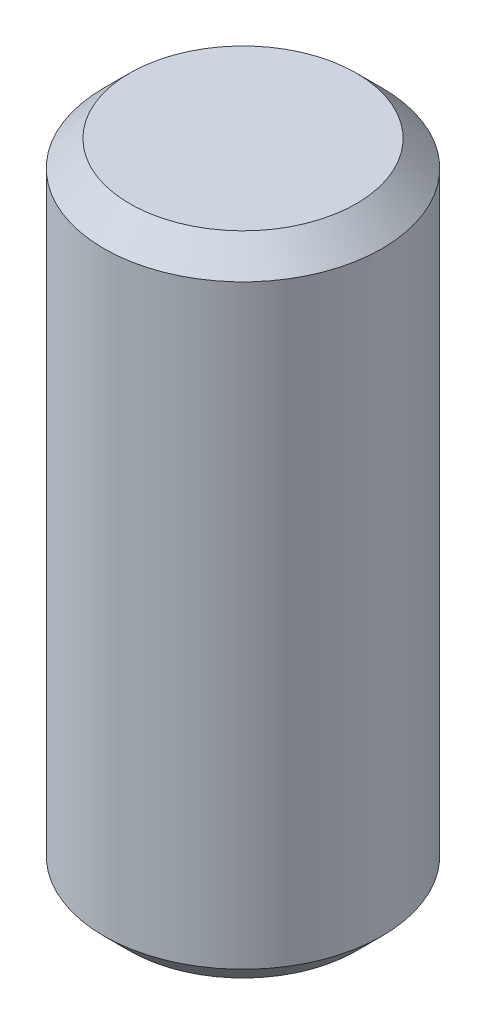
from build123d import *

# Parameters (mm, degrees)
SKETCH1_W     = 2.7305
SKETCH1_H     = 12.7
CHAMFER1_SIZE = 0.508


with BuildPart() as part:
    # Sketch1 → Revolve1 (revolve)
    with BuildSketch(Plane.XY):
        with Locations((1.36525, 0)):
            Rectangle(SKETCH1_W, SKETCH1_H)
    revolve(axis=Axis((0, 6.080207887, 0), (0, -1, 0)))

    # Chamfer1
    chamfer1_edges = [part.edges().sort_by_distance(p)[0] for p in [
        (-2.7305, 6.35, 0),
        (-2.7305, -6.35, 0),
    ]]
    chamfer(chamfer1_edges, length=CHAMFER1_SIZE)


solid = part.part
